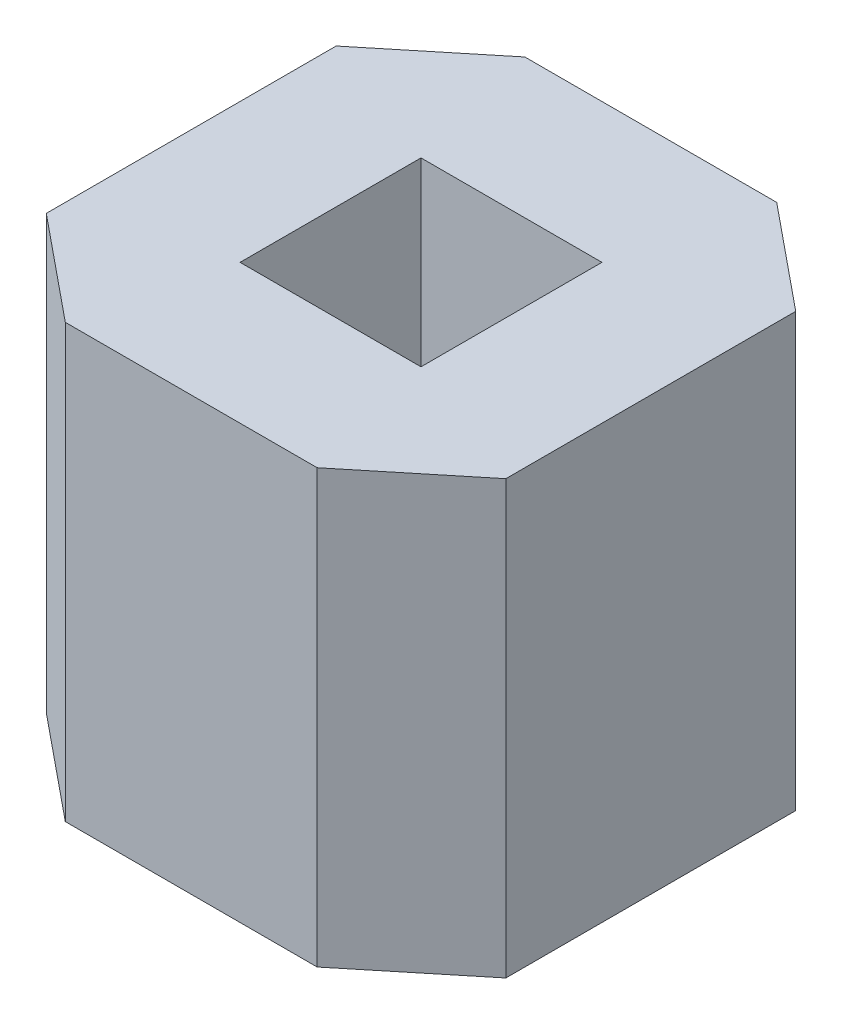
from build123d import *

# Parameters (mm, degrees)
SKETCH1_W           = 1
SKETCH1_H           = 1
BOSS_EXTRUDE2_DEPTH = 2.39


with BuildPart() as part:
    # Sketch1 → Boss-Extrude2 (new body)
    with BuildSketch(Plane(origin=(0, 0, 0), x_dir=(1, 0, 0), z_dir=(0, 1, 0))):
        Polygon((-39.218854462, 3.923726072), (-37.826970459, 3.923726072), (-37.252912461, 4.392648439), (-37.252912461, 5.994803705), (-37.826970459, 6.463726072), (-39.218854462, 6.463726072), (-39.792912461, 5.994803705), (-39.792912461, 4.392648439), align=None)
        with Locations((-38.522912461, 5.193726072)):
            Rectangle(SKETCH1_W, SKETCH1_H, mode=Mode.SUBTRACT)
    extrude(amount=BOSS_EXTRUDE2_DEPTH)


solid = part.part
